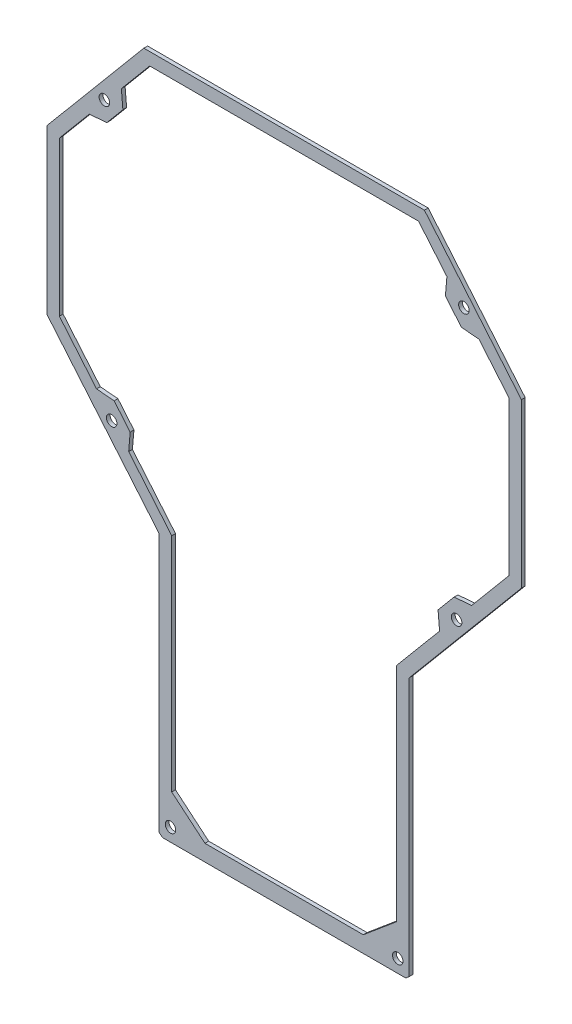
from build123d import *

# Parameters (mm, degrees)
RESSALTO_EXTRUS_O1_DEPTH = 1.5
CORTE_EXTRUS_O1_REACH    = 3.5
ESBO_O2_R                = 2.1
CORTE_EXTRUS_O2_DEPTH    = 10


with BuildPart() as part:
    # Esboço1 → Ressalto-extrusão1 (new body)
    with BuildSketch(Plane.XY):
        Polygon((56.463679973, 135.159747673), (-55.864365487, 135.159747673), (-94.700342757, 88.87683224), (-94.700342757, 23.490318666), (-49.700342757, -30.138593001), (-49.700342757, -133.732537696), (-48.380219867, -134.840252327), (48.979534352, -134.840252327), (50.299657243, -133.732537696), (50.299657243, -30.138593001), (95.299657243, 23.490318666), (95.299657243, 88.87683224), align=None)
    extrude(amount=RESSALTO_EXTRUS_O1_DEPTH)

    # Esboço2 → Corte-extrusão1 (cut, up to next)
    with BuildSketch(Plane.XY.offset(1.5), mode=Mode.PRIVATE) as corte_extrus_o1_sk1:
        with Locations((-71.672714117, 109.298736063)):
            Circle(ESBO_O2_R)
    corte_extrus_o1_tool1 = extrude(corte_extrus_o1_sk1.sketch, amount=-CORTE_EXTRUS_O1_REACH, mode=Mode.PRIVATE) & part.part
    add(corte_extrus_o1_tool1.solids().sort_by_distance((-71.672714, 109.298736, 1.5))[0], mode=Mode.SUBTRACT)
    # Esboço2 → Corte-extrusão1 (cut, up to next)
    with BuildSketch(Plane.XY.offset(1.5), mode=Mode.PRIVATE) as corte_extrus_o1_sk2:
        with Locations((-45.200342757, -129.610252327)):
            Circle(ESBO_O2_R)
    corte_extrus_o1_tool2 = extrude(corte_extrus_o1_sk2.sketch, amount=-CORTE_EXTRUS_O1_REACH, mode=Mode.PRIVATE) & part.part
    add(corte_extrus_o1_tool2.solids().sort_by_distance((-45.200343, -129.610252, 1.5))[0], mode=Mode.SUBTRACT)
    # Esboço2 → Corte-extrusão1 (cut, up to next)
    with BuildSketch(Plane.XY.offset(1.5), mode=Mode.PRIVATE) as corte_extrus_o1_sk3:
        with Locations((45.799657243, -129.610252327)):
            Circle(ESBO_O2_R)
    corte_extrus_o1_tool3 = extrude(corte_extrus_o1_sk3.sketch, amount=-CORTE_EXTRUS_O1_REACH, mode=Mode.PRIVATE) & part.part
    add(corte_extrus_o1_tool3.solids().sort_by_distance((45.799657, -129.610252, 1.5))[0], mode=Mode.SUBTRACT)
    # Esboço2 → Corte-extrusão1 (cut, up to next)
    with BuildSketch(Plane.XY.offset(1.5), mode=Mode.PRIVATE) as corte_extrus_o1_sk4:
        with Locations((72.272028603, 109.298736063)):
            Circle(ESBO_O2_R)
    corte_extrus_o1_tool4 = extrude(corte_extrus_o1_sk4.sketch, amount=-CORTE_EXTRUS_O1_REACH, mode=Mode.PRIVATE) & part.part
    add(corte_extrus_o1_tool4.solids().sort_by_distance((72.272029, 109.298736, 1.5))[0], mode=Mode.SUBTRACT)
    # Esboço2 → Corte-extrusão1 (cut, up to next)
    with BuildSketch(Plane.XY.offset(1.5), mode=Mode.PRIVATE) as corte_extrus_o1_sk5:
        with Locations((-68.753142763, -0.431592924)):
            Circle(ESBO_O2_R)
    corte_extrus_o1_tool5 = extrude(corte_extrus_o1_sk5.sketch, amount=-CORTE_EXTRUS_O1_REACH, mode=Mode.PRIVATE) & part.part
    add(corte_extrus_o1_tool5.solids().sort_by_distance((-68.753143, -0.431593, 1.5))[0], mode=Mode.SUBTRACT)
    # Esboço2 → Corte-extrusão1 (cut, up to next)
    with BuildSketch(Plane.XY.offset(1.5), mode=Mode.PRIVATE) as corte_extrus_o1_sk6:
        with Locations((69.352457249, -0.431592924)):
            Circle(ESBO_O2_R)
    corte_extrus_o1_tool6 = extrude(corte_extrus_o1_sk6.sketch, amount=-CORTE_EXTRUS_O1_REACH, mode=Mode.PRIVATE) & part.part
    add(corte_extrus_o1_tool6.solids().sort_by_distance((69.352457, -0.431593, 1.5))[0], mode=Mode.SUBTRACT)

    # Esboço3 → Corte-extrusão2 (cut)
    with BuildSketch(Plane.XY.offset(1.5)):
        Polygon((-53.532827197, 130.159747673), (-64.879577854, 116.637216813), (-64.263293687, 109.593056549), (-70.675930858, 101.950773162), (-77.720091122, 101.334488995), (-89.700342757, 87.056981069), (-89.700342757, 25.310169837), (-74.789956765, 7.540663764), (-67.745796501, 6.924379597), (-61.334000151, -0.716901738), (-61.950284318, -7.761062002), (-44.700342757, -28.318741829), (-44.700342757, -117.173246706), (-31.407709232, -128.327090595), (32.007023717, -128.327090595), (45.299657243, -117.173246706), (45.299657243, -28.318741829), (62.549598803, -7.761062002), (61.933314636, -0.716901738), (68.345110987, 6.924379597), (75.389271251, 7.540663764), (90.299657243, 25.310169837), (90.299657243, 87.056981069), (78.319405608, 101.334488995), (71.275245343, 101.950773162), (64.862608173, 109.593056549), (65.47889234, 116.637216813), (54.132141682, 130.159747673), align=None)
    extrude(amount=-CORTE_EXTRUS_O2_DEPTH, mode=Mode.SUBTRACT)


solid = part.part
